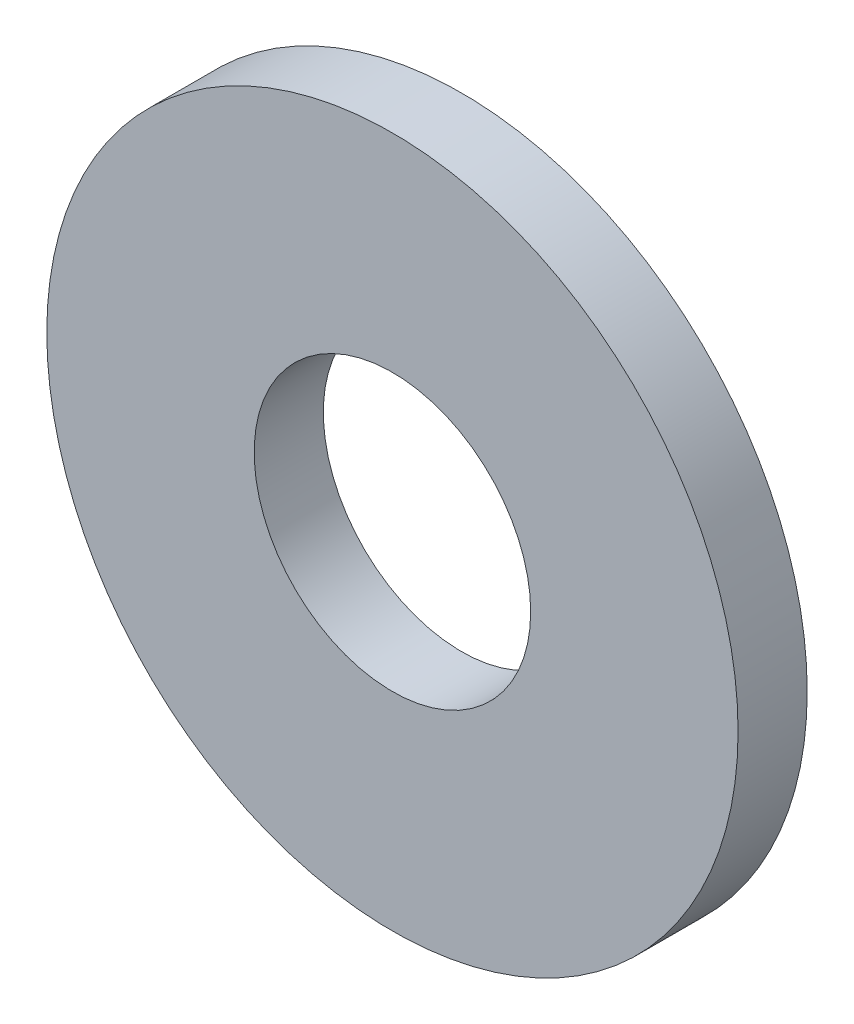
from build123d import *

# Parameters (mm, degrees)
SKETCH1_R           = 7.9375
SKETCH1_R_2         = 3.175
BOSS_EXTRUDE1_DEPTH = 1.5875


with BuildPart() as part:
    # Sketch1 → Boss-Extrude1 (new body)
    with BuildSketch(Plane.XY):
        Circle(SKETCH1_R)
        Circle(SKETCH1_R_2, mode=Mode.SUBTRACT)
    extrude(amount=BOSS_EXTRUDE1_DEPTH)


solid = part.part
